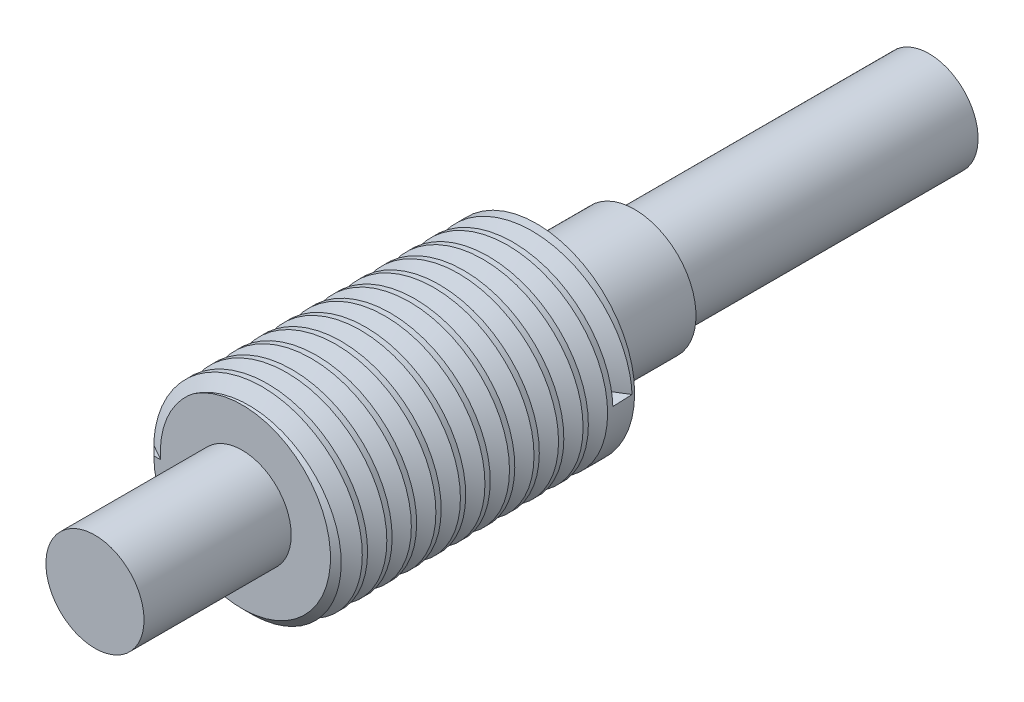
from build123d import *

# Parameters (mm, degrees)
SKETCH1_R           = 1
BOSS_EXTRUDE1_DEPTH = 3
CHAMFER1_SIZE       = 0.1
CUT_SWEEP1_PITCH    = 0.25
CUT_SWEEP1_HEIGHT   = 2.875
CUT_SWEEP1_RADIUS   = 1
SKETCH5_R           = 0.625
BOSS_EXTRUDE2_DEPTH = 1
SKETCH6_R           = 0.5
BOSS_EXTRUDE3_DEPTH = 3
SKETCH7_R           = 0.5
BOSS_EXTRUDE4_DEPTH = 1.5


with BuildPart() as part:
    # Sketch1 → Boss-Extrude1 (new body)
    with BuildSketch(Plane.XY):
        Circle(SKETCH1_R)
    extrude(amount=BOSS_EXTRUDE1_DEPTH)

    # Chamfer1
    chamfer1_edges = [part.edges().sort_by_distance(p)[0] for p in [
        (-1, 0, 3),
    ]]
    chamfer(chamfer1_edges, length=CHAMFER1_SIZE)

    # Cut-Sweep1: sweep along a helix
    with BuildLine() as cut_sweep1_path:
        Helix(CUT_SWEEP1_PITCH, CUT_SWEEP1_HEIGHT, CUT_SWEEP1_RADIUS, center=(0, 0, 3), direction=(0, 0, -1))
    # Sketch4 → Cut-Sweep1 (sweep, cut)
    with BuildSketch(Plane(origin=(-1, 0, 3), x_dir=(1, 0, 0), z_dir=(0, 0.999209367, -0.039757277))):
        Polygon((0.169672393, 0.000618554), (-0.020853196, 0.110618554), (-0.020853196, -0.109381446), align=None)
    sweep(path=cut_sweep1_path.line, is_frenet=True, mode=Mode.SUBTRACT)

    # Sketch5 → Boss-Extrude2 (add)
    with BuildSketch(Plane(origin=(0, 0, 0), x_dir=(-1, 0, 0), z_dir=(0, 0, -1))):
        Circle(SKETCH5_R)
    extrude(amount=BOSS_EXTRUDE2_DEPTH)

    # Sketch6 → Boss-Extrude3 (add)
    with BuildSketch(Plane(origin=(0, 0, -1), x_dir=(-1, 0, 0), z_dir=(0, 0, -1))):
        Circle(SKETCH6_R)
    extrude(amount=BOSS_EXTRUDE3_DEPTH)

    # Sketch7 → Boss-Extrude4 (add)
    with BuildSketch(Plane.XY.offset(3)):
        Circle(SKETCH7_R)
    extrude(amount=BOSS_EXTRUDE4_DEPTH)


solid = part.part
